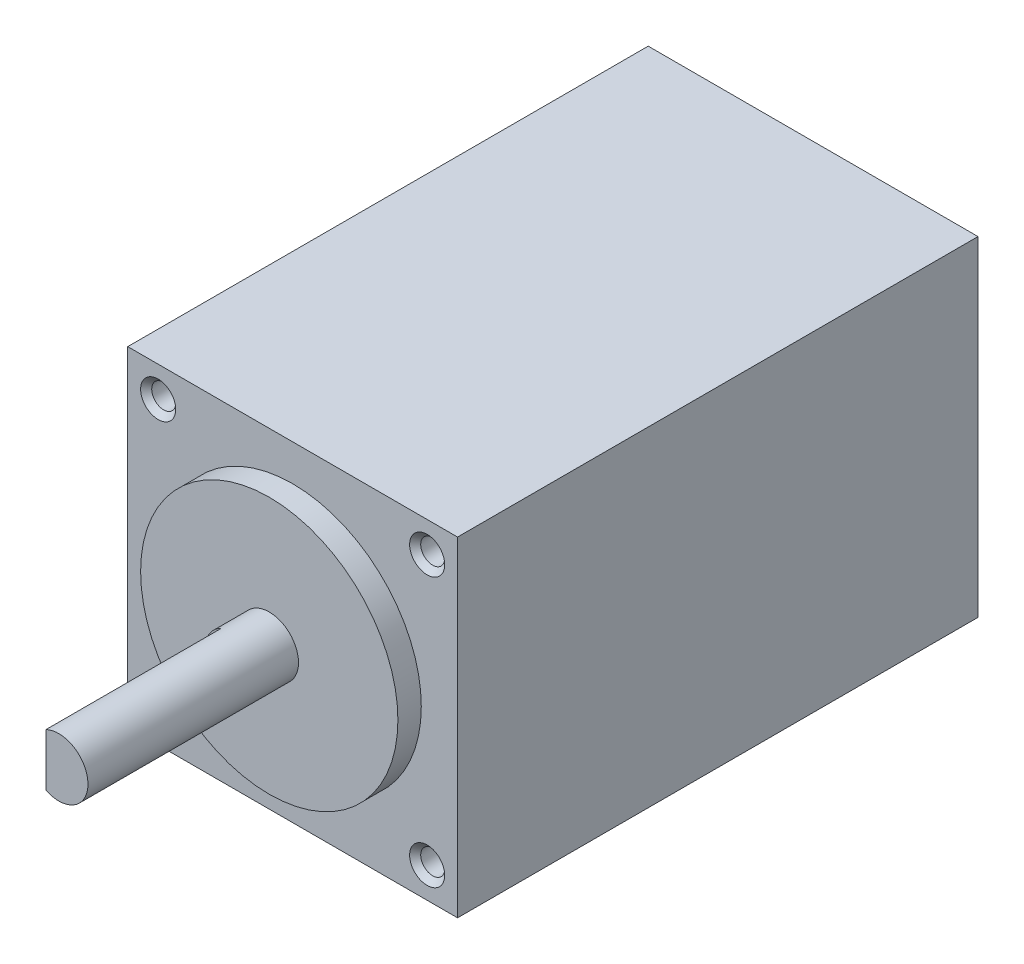
from build123d import *

# Parameters (mm, degrees)
SKETCH1_W                          = 28.2
SKETCH1_H                          = 28.2
BOSS_EXTRUDE1_DEPTH                = 44.5
M2_5X0_45_TAPPED_HOLE1_D           = 2.05
M2_5X0_45_TAPPED_HOLE1_DEPTH       = 6.4
M2_5X0_45_TAPPED_HOLE1_CSINK_D     = 3
M2_5X0_45_TAPPED_HOLE1_CSINK_ANGLE = 90
M2_5X0_45_TAPPED_HOLE1_TIP         = 0.615882135
SKETCH15_R                         = 11
BOSS_EXTRUDE2_DEPTH                = 2
SKETCH16_R                         = 2.5
BOSS_EXTRUDE3_DEPTH                = 18
CUT_EXTRUDE1_DEPTH                 = 15


with BuildPart() as part:
    # Sketch1 → Boss-Extrude1 (new body)
    with BuildSketch(Plane.XY):
        with Locations((14.1, 14.1)):
            Rectangle(SKETCH1_W, SKETCH1_H)
    extrude(amount=BOSS_EXTRUDE1_DEPTH)

    # M2.5x0.45 Tapped Hole1
    with Locations(Plane.XY.offset(44.5)):
        with Locations((25.6, 2.6), (25.6, 25.6), (2.6, 2.6), (2.6, 25.6)):
            CounterSinkHole(M2_5X0_45_TAPPED_HOLE1_D / 2, M2_5X0_45_TAPPED_HOLE1_CSINK_D / 2, depth=M2_5X0_45_TAPPED_HOLE1_DEPTH, counter_sink_angle=M2_5X0_45_TAPPED_HOLE1_CSINK_ANGLE)
            with Locations((0, 0, -(M2_5X0_45_TAPPED_HOLE1_DEPTH + M2_5X0_45_TAPPED_HOLE1_TIP / 2))):  # 118° drill point
                Cone(0, M2_5X0_45_TAPPED_HOLE1_D / 2, M2_5X0_45_TAPPED_HOLE1_TIP, mode=Mode.SUBTRACT)

    # Sketch15 → Boss-Extrude2 (add)
    with BuildSketch(Plane.XY.offset(44.5)):
        with Locations((14.1, 14.1)):
            Circle(SKETCH15_R)
    extrude(amount=BOSS_EXTRUDE2_DEPTH)

    # Sketch16 → Boss-Extrude3 (add)
    with BuildSketch(Plane.XY.offset(46.5)):
        with Locations((14.1, 14.1)):
            Circle(SKETCH16_R)
    extrude(amount=BOSS_EXTRUDE3_DEPTH)

    # Sketch17 → Cut-Extrude1 (cut)
    with BuildSketch(Plane.XY.offset(64.5)):
        with BuildLine():
            Line((13.010275264, 16.35), (13.010275264, 11.85))
            ThreePointArc((13.010275264, 11.85), (11.6, 14.1), (13.010275264, 16.35))
        make_face()
    extrude(amount=-CUT_EXTRUDE1_DEPTH, mode=Mode.SUBTRACT)


solid = part.part
